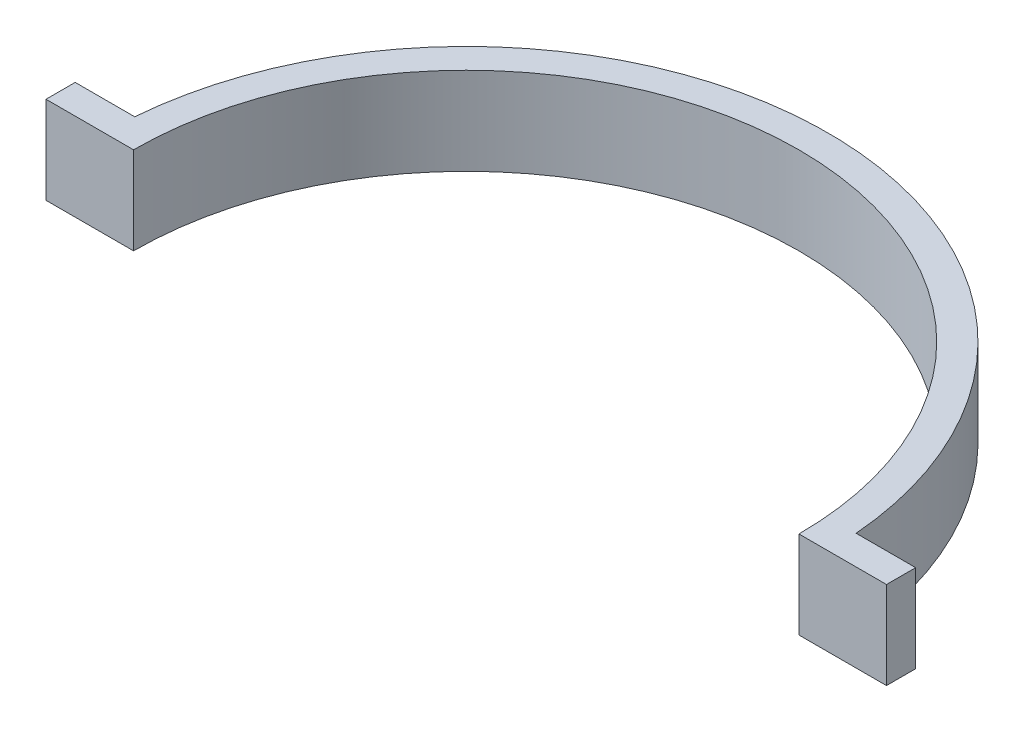
from build123d import *

# Parameters (mm, degrees)
SKETCH1_W                = 3.175
SKETCH1_H                = 9.525
REVOLVE1_ANGLE           = 180
BOSS_EXTRUDE1_REACH      = 90.163
BOSS_EXTRUDE1_END_RADIUS = 39.37
SKETCH2_W                = 3.175
SKETCH2_H                = 9.525
SKETCH2_2_W              = 3.175
SKETCH2_2_H              = 9.525
BOSS_EXTRUDE2_DEPTH      = 6.35
BOSS_EXTRUDE3_REACH      = 95.878
BOSS_EXTRUDE3_END_RADIUS = 39.37
SKETCH4_W                = 3.175
SKETCH4_H                = 9.525
SKETCH4_2_W              = 3.175
SKETCH4_2_H              = 9.525
BOSS_EXTRUDE4_DEPTH      = 6.35


with BuildPart() as part:
    # Sketch1 → Revolve1 (revolve)
    with BuildSketch(Plane.XY):
        with Locations((37.7825, 0)):
            Rectangle(SKETCH1_W, SKETCH1_H)
    revolve(axis=Axis((0, -72.106361407, 0), (0, 1, 0)), revolution_arc=REVOLVE1_ANGLE)

    # Boss-Extrude1: up to this cylinder (the profile starts outside it)
    boss_extrude1_end = Plane(origin=(0, 0, 0), z_dir=(0, -1, 0)) * Cylinder(BOSS_EXTRUDE1_END_RADIUS, 260.066, mode=Mode.PRIVATE)
    # Sketch2 → Boss-Extrude1 (add, up to the surface)
    with BuildSketch(Plane(origin=(39.37, 0, 0), x_dir=(0, 0, -1), z_dir=(1, 0, 0)), mode=Mode.PRIVATE) as boss_extrude1_sk1:
        with Locations((1.5875, 0)):
            Rectangle(SKETCH2_W, SKETCH2_H)
    boss_extrude1_tool1 = extrude(boss_extrude1_sk1.sketch, amount=-BOSS_EXTRUDE1_REACH, mode=Mode.PRIVATE) - boss_extrude1_end
    add(boss_extrude1_tool1.solids().sort_by_distance((39.37, 0, -1.5875))[0])

    # Sketch2_2 → Boss-Extrude2 (add)
    with BuildSketch(Plane(origin=(39.37, 0, 0), x_dir=(0, 0, -1), z_dir=(1, 0, 0))):
        with Locations((1.5875, 0)):
            Rectangle(SKETCH2_2_W, SKETCH2_2_H)
    extrude(amount=BOSS_EXTRUDE2_DEPTH)

    # Boss-Extrude3: up to this cylinder (the profile starts outside it)
    boss_extrude3_end = Plane(origin=(0, 0, 0), z_dir=(0, -1, 0)) * Cylinder(BOSS_EXTRUDE3_END_RADIUS, 271.496, mode=Mode.PRIVATE)
    # Sketch4 → Boss-Extrude3 (add, up to the surface)
    with BuildSketch(Plane.ZY.offset(39.37), mode=Mode.PRIVATE) as boss_extrude3_sk1:
        with Locations((-1.5875, 0)):
            Rectangle(SKETCH4_W, SKETCH4_H)
    boss_extrude3_tool1 = extrude(boss_extrude3_sk1.sketch, amount=-BOSS_EXTRUDE3_REACH, mode=Mode.PRIVATE) - boss_extrude3_end
    add(boss_extrude3_tool1.solids().sort_by_distance((-39.37, 0, -1.5875))[0])

    # Sketch4_2 → Boss-Extrude4 (add)
    with BuildSketch(Plane.ZY.offset(39.37)):
        with Locations((-1.5875, 0)):
            Rectangle(SKETCH4_2_W, SKETCH4_2_H)
    extrude(amount=BOSS_EXTRUDE4_DEPTH)


solid = part.part
